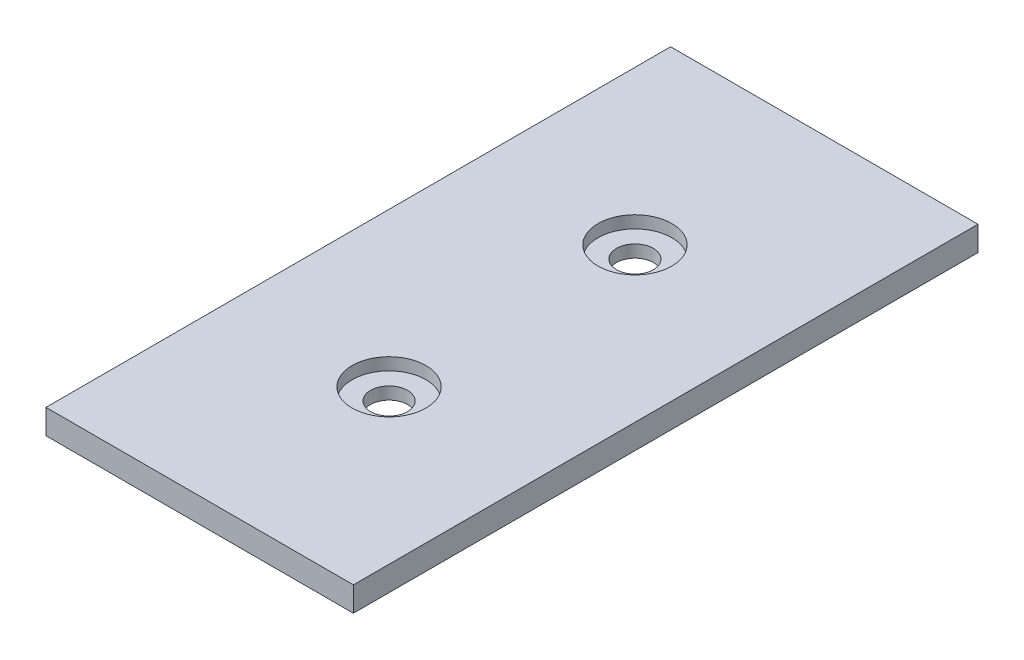
from build123d import *

# Parameters (mm, degrees)
SKETCH1_W           = 50
SKETCH1_H           = 101.6
BOSS_EXTRUDE1_DEPTH = 4
SKETCH2_R           = 3
CUT_EXTRUDE1_DEPTH  = 10
SKETCH3_R           = 6
CUT_EXTRUDE2_DEPTH  = 2


with BuildPart() as part:
    # Sketch1 → Boss-Extrude1 (new body)
    with BuildSketch(Plane(origin=(0, 0, 0), x_dir=(1, 0, 0), z_dir=(0, 1, 0))):
        Rectangle(SKETCH1_W, SKETCH1_H)
    extrude(amount=BOSS_EXTRUDE1_DEPTH)

    # Sketch2 → Cut-Extrude1 (cut)
    with BuildSketch(Plane(origin=(0, 4, 0), x_dir=(1, 0, 0), z_dir=(0, 1, 0))):
        with Locations((0, 20)):
            Circle(SKETCH2_R)
        with Locations((0, -20)):
            Circle(SKETCH2_R)
    extrude(amount=-CUT_EXTRUDE1_DEPTH, mode=Mode.SUBTRACT)

    # Sketch3 → Cut-Extrude2 (cut)
    with BuildSketch(Plane(origin=(0, 4, 0), x_dir=(1, 0, 0), z_dir=(0, 1, 0))):
        with Locations((0, 20)):
            Circle(SKETCH3_R)
        with Locations((0, -20)):
            Circle(SKETCH3_R)
    extrude(amount=-CUT_EXTRUDE2_DEPTH, mode=Mode.SUBTRACT)


solid = part.part
